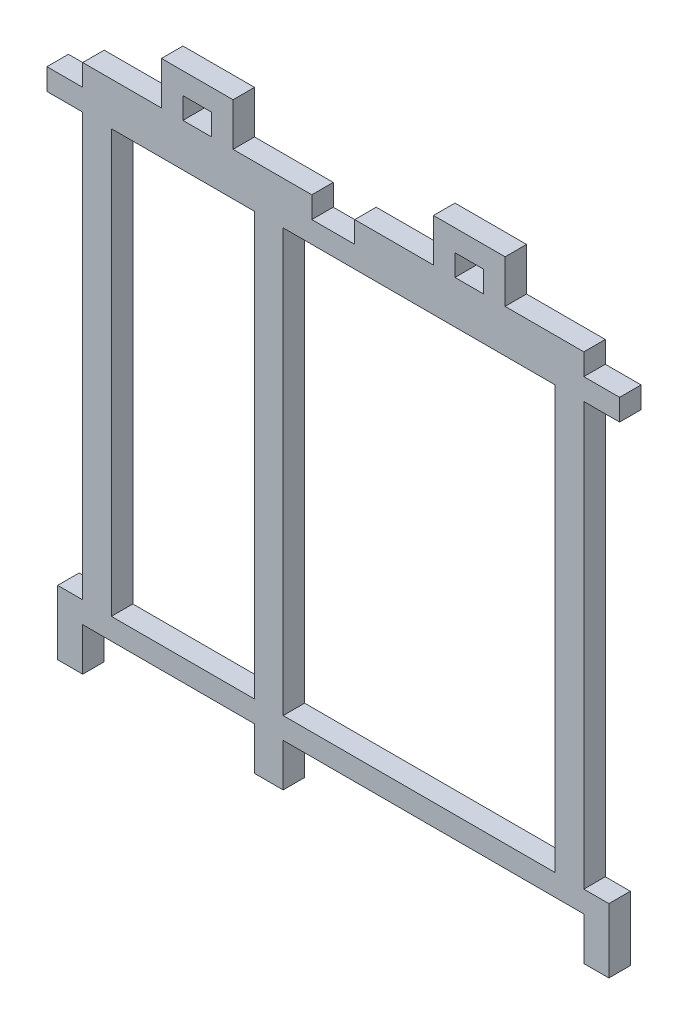
from build123d import *

# Parameters (mm, degrees)
SKETCH1_W           = 20
SKETCH1_H           = 59
SKETCH1_W_2         = 38
BOSS_EXTRUDE1_DEPTH = 3
BOSS_EXTRUDE2_DEPTH = 3


with BuildPart() as part:
    # Sketch1 → Boss-Extrude1 (new body)
    with BuildSketch(Plane.XY):
        Polygon((5, -3), (0, -3), (0, 0), (5, 0), (5, 3), (37, 3), (37, 0), (43, 0), (43, 3), (75, 3), (75, 0), (80, 0), (80, -3), (75, -3), (75, -62), (78.5, -62), (78.5, -71), (75, -71), (75, -65), (33, -65), (33, -71), (29, -71), (29, -65), (5, -65), (5, -71), (1.5, -71), (1.5, -62), (5, -62), align=None)
        with Locations((19, -32.5)):
            Rectangle(SKETCH1_W, SKETCH1_H, mode=Mode.SUBTRACT)
        with Locations((52, -32.5)):
            Rectangle(SKETCH1_W_2, SKETCH1_H, mode=Mode.SUBTRACT)
    extrude(amount=BOSS_EXTRUDE1_DEPTH)

    # Sketch2 → Boss-Extrude2 (add)
    with BuildSketch(Plane.XY.offset(3)):
        Polygon((16, 9), (16, 3), (19, 3), (19, 6), (23, 6), (23, 3), (26, 3), (26, 9), align=None)
        Polygon((54, 3), (57, 3), (57, 6), (61, 6), (61, 3), (64, 3), (64, 9), (54, 9), align=None)
    extrude(amount=-BOSS_EXTRUDE2_DEPTH)


solid = part.part
